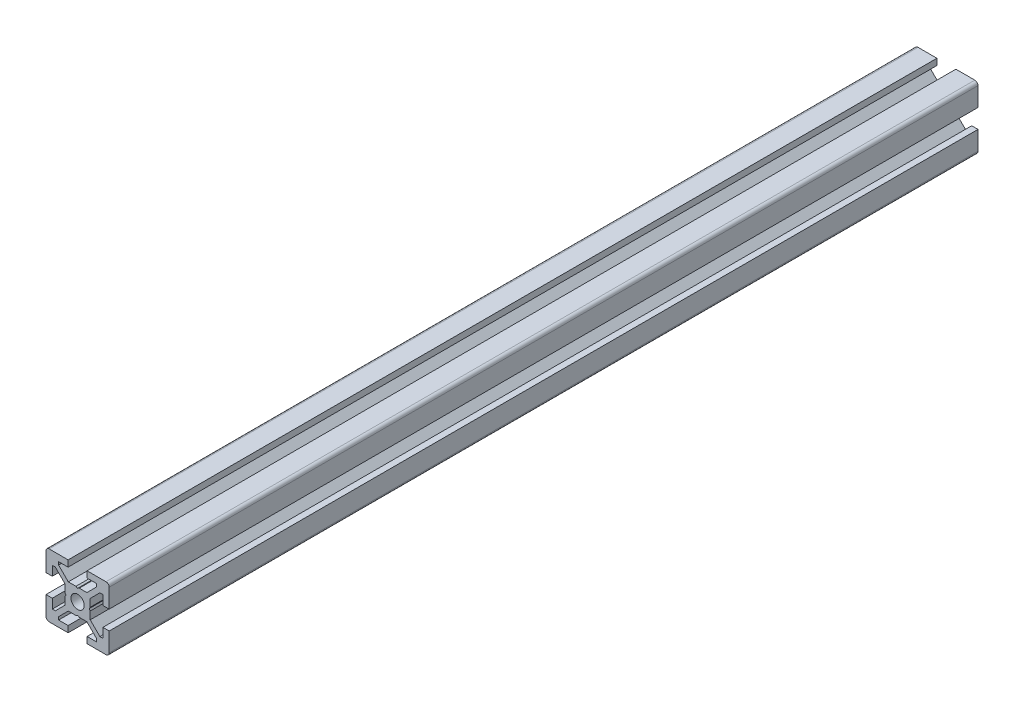
from build123d import *

# Parameters (mm, degrees)
EXTRUDE_1_DEPTH = 275
SKETCH_2_W      = 260
SKETCH_2_H      = 2.1


with BuildPart() as part:
    # ｽｹｯﾁ1 → ﾎﾞｽ - 押し出し1 (new body)
    with BuildSketch(Plane.XY):
        with BuildLine():
            Line((-10, -3), (-10, -9))
            ThreePointArc((-10, -9), (-9.707106781, -9.707106781), (-9, -10))
            Line((-9, -10), (-3, -10))
            Line((-3, -10), (-3, -8))
            Line((-3, -8), (-6, -8))
            Line((-6, -8), (-6, -7.060660172))
            Line((-6, -7.060660172), (-2.939339828, -4))
            Line((-2.939339828, -4), (-0.519615242, -4))
            Line((-0.519615242, -4), (0, -3.7))
            Line((0, -3.7), (0.519615242, -4))
            Line((0.519615242, -4), (2.939339828, -4))
            Line((2.939339828, -4), (6, -7.060660172))
            Line((6, -7.060660172), (6, -8))
            Line((6, -8), (3, -8))
            Line((3, -8), (3, -10))
            Line((3, -10), (9, -10))
            ThreePointArc((9, -10), (9.707106781, -9.707106781), (10, -9))
            Line((10, -9), (10, -3))
            Line((10, -3), (8, -3))
            Line((8, -3), (8, -6))
            Line((8, -6), (7.060660172, -6))
            Line((7.060660172, -6), (4, -2.939339828))
            Line((4, -2.939339828), (4, -0.519615242))
            Line((4, -0.519615242), (3.7, 0))
            Line((3.7, 0), (4, 0.519615242))
            Line((4, 0.519615242), (4, 2.939339828))
            Line((4, 2.939339828), (7.060660172, 6))
            Line((7.060660172, 6), (8, 6))
            Line((8, 6), (8, 3))
            Line((8, 3), (10, 3))
            Line((10, 3), (10, 9))
            ThreePointArc((10, 9), (9.707106781, 9.707106781), (9, 10))
            Line((9, 10), (3, 10))
            Line((3, 10), (3, 8))
            Line((3, 8), (6, 8))
            Line((6, 8), (6, 7.060660172))
            Line((6, 7.060660172), (2.939339828, 4))
            Line((2.939339828, 4), (0.519615242, 4))
            Line((0.519615242, 4), (0, 3.7))
            Line((0, 3.7), (-0.519615242, 4))
            Line((-0.519615242, 4), (-2.939339828, 4))
            Line((-2.939339828, 4), (-6, 7.060660172))
            Line((-6, 7.060660172), (-6, 8))
            Line((-6, 8), (-3, 8))
            Line((-3, 8), (-3, 10))
            Line((-3, 10), (-9, 10))
            ThreePointArc((-9, 10), (-9.707106781, 9.707106781), (-10, 9))
            Line((-10, 9), (-10, 3))
            Line((-10, 3), (-8, 3))
            Line((-8, 3), (-8, 6))
            Line((-8, 6), (-7.060660172, 6))
            Line((-7.060660172, 6), (-4, 2.939339828))
            Line((-4, 2.939339828), (-4, 0.519615242))
            Line((-4, 0.519615242), (-3.7, 0))
            Line((-3.7, 0), (-4, -0.519615242))
            Line((-4, -0.519615242), (-4, -2.939339828))
            Line((-4, -2.939339828), (-7.060660172, -6))
            Line((-7.060660172, -6), (-8, -6))
            Line((-8, -6), (-8, -3))
            Line((-8, -3), (-10, -3))
        make_face()
    extrude(amount=-EXTRUDE_1_DEPTH)

    # ｽｹｯﾁ2 → ｶｯﾄ - 回転1 (revolve, cut)
    with BuildSketch(Plane(origin=(0, 0, 0), x_dir=(0, 0, -1), z_dir=(1, 0, 0))):
        with Locations((130, 1.05)):
            Rectangle(SKETCH_2_W, SKETCH_2_H)
    revolve(axis=Axis((0, 0, -260), (0, 0, 1)), mode=Mode.SUBTRACT)


solid = part.part
